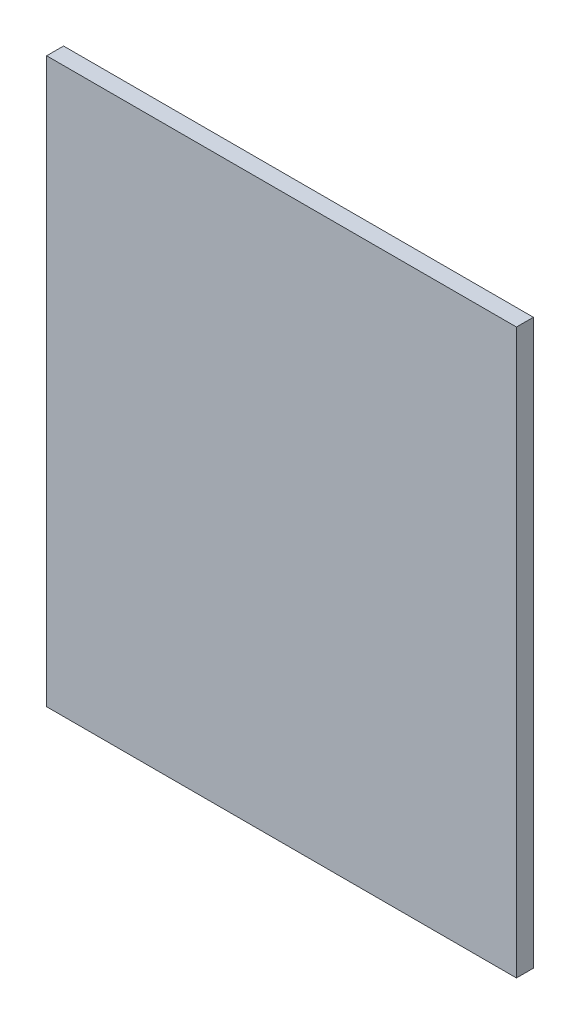
from build123d import *

# Parameters (mm, degrees)
SKETCH1_W           = 500
SKETCH1_H           = 600
BOSS_EXTRUDE1_DEPTH = 18


with BuildPart() as part:
    # Sketch1 → Boss-Extrude1 (new body)
    with BuildSketch(Plane.XY):
        Rectangle(SKETCH1_W, SKETCH1_H)
    extrude(amount=BOSS_EXTRUDE1_DEPTH)


solid = part.part
